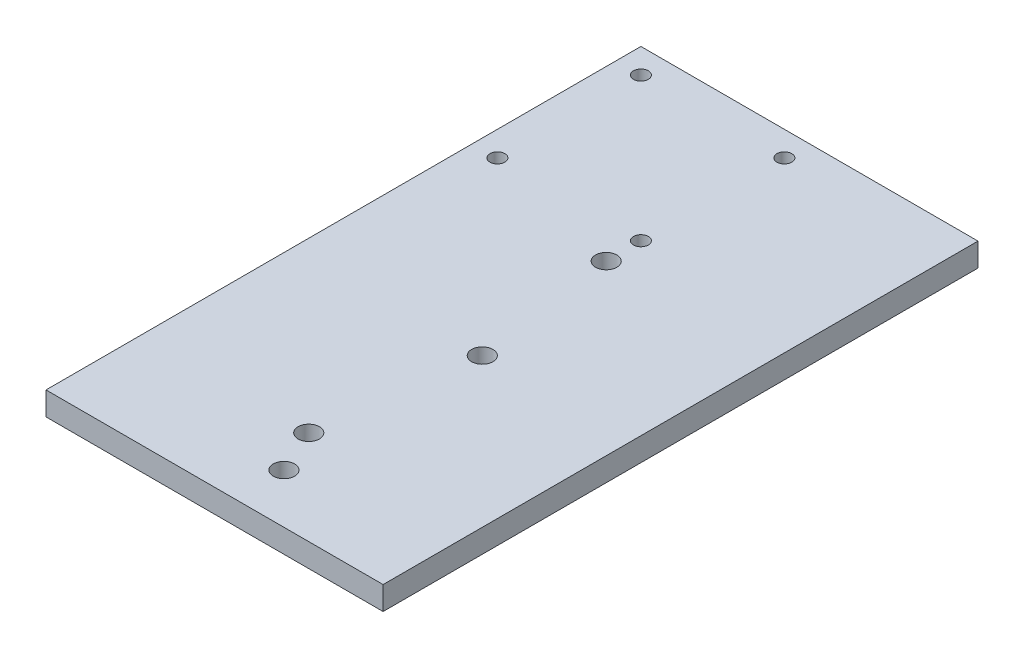
from build123d import *

# Parameters (mm, degrees)
SKETCH2_W               = 88.9
SKETCH2_H               = 152.4
BOSS_EXTRUDE1_DEPTH     = 5.9944
SKETCH4_R               = 2.7305
CUT_EXTRUDE2_DEPTH      = 1
CUT_EXTRUDE2_DEPTH_BACK = 6.9944
SKETCH5_R               = 2.7305
CUT_EXTRUDE3_DEPTH      = 1
CUT_EXTRUDE3_DEPTH_BACK = 6.9944
SKETCH6_R               = 1.905
CUT_EXTRUDE4_DEPTH      = 1
CUT_EXTRUDE4_DEPTH_BACK = 6.9944
SKETCH7_W               = 2.54
SKETCH7_H               = 152.4
CUT_EXTRUDE5_DEPTH      = 1
CUT_EXTRUDE5_DEPTH_BACK = 6.9944


with BuildPart() as part:
    # Sketch2 → Boss-Extrude1 (new body)
    with BuildSketch(Plane(origin=(0, 0, 0), x_dir=(1, 0, 0), z_dir=(0, 1, 0))):
        with Locations((44.45, 76.2)):
            Rectangle(SKETCH2_W, SKETCH2_H)
    extrude(amount=BOSS_EXTRUDE1_DEPTH)

    # Sketch4 → Cut-Extrude2 (cut, two sides)
    with BuildSketch(Plane(origin=(0, 5.9944, 0), x_dir=(1, 0, 0), z_dir=(0, 1, 0))) as cut_extrude2_sk:
        with Locations((45.72, 100.33)):
            Circle(SKETCH4_R)
        with Locations((45.72, 24.13)):
            Circle(SKETCH4_R)
    extrude(amount=CUT_EXTRUDE2_DEPTH, mode=Mode.SUBTRACT)
    extrude(cut_extrude2_sk.sketch, amount=-CUT_EXTRUDE2_DEPTH_BACK, mode=Mode.SUBTRACT)

    # Sketch5 → Cut-Extrude3 (cut, two sides)
    with BuildSketch(Plane(origin=(0, 5.9944, 0), x_dir=(1, 0, 0), z_dir=(0, 1, 0))) as cut_extrude3_sk:
        with Locations((50.8, 63.5)):
            Circle(SKETCH5_R)
        with Locations((50.8, 12.7)):
            Circle(SKETCH5_R)
    extrude(amount=CUT_EXTRUDE3_DEPTH, mode=Mode.SUBTRACT)
    extrude(cut_extrude3_sk.sketch, amount=-CUT_EXTRUDE3_DEPTH_BACK, mode=Mode.SUBTRACT)

    # Sketch6 → Cut-Extrude4 (cut, two sides)
    with BuildSketch(Plane(origin=(0, 5.9944, 0), x_dir=(1, 0, 0), z_dir=(0, 1, 0))) as cut_extrude4_sk:
        with Locations((45.6438, 109.2962)):
            Circle(SKETCH6_R)
        with Locations((8.89, 109.2962)):
            Circle(SKETCH6_R)
        with Locations((8.89, 146.05)):
            Circle(SKETCH6_R)
        with Locations((45.6438, 146.05)):
            Circle(SKETCH6_R)
    extrude(amount=CUT_EXTRUDE4_DEPTH, mode=Mode.SUBTRACT)
    extrude(cut_extrude4_sk.sketch, amount=-CUT_EXTRUDE4_DEPTH_BACK, mode=Mode.SUBTRACT)

    # Sketch7 → Cut-Extrude5 (cut, two sides)
    with BuildSketch(Plane(origin=(0, 5.9944, 0), x_dir=(1, 0, 0), z_dir=(0, 1, 0))) as cut_extrude5_sk:
        with Locations((1.27, 76.2)):
            Rectangle(SKETCH7_W, SKETCH7_H)
    extrude(amount=CUT_EXTRUDE5_DEPTH, mode=Mode.SUBTRACT)
    extrude(cut_extrude5_sk.sketch, amount=-CUT_EXTRUDE5_DEPTH_BACK, mode=Mode.SUBTRACT)


solid = part.part
